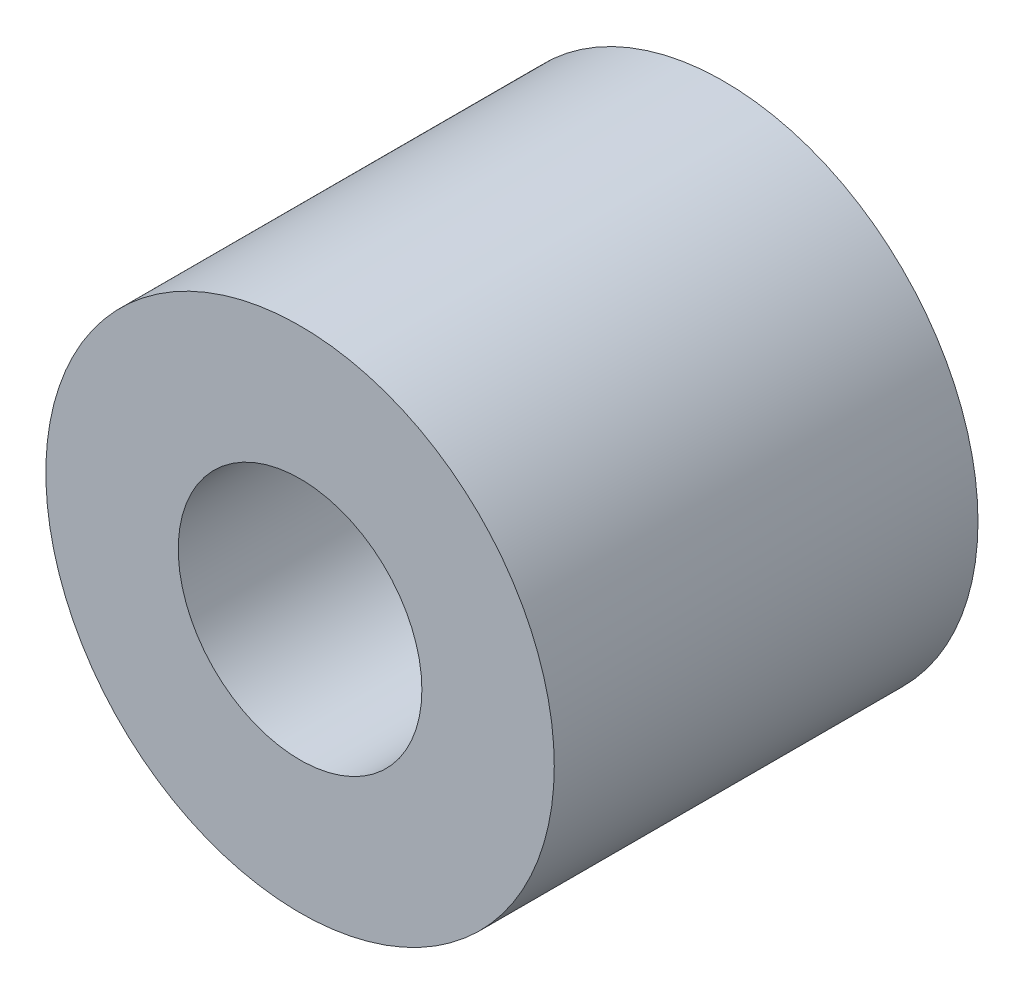
from build123d import *

# Parameters (mm, degrees)
SKETCH_1_R      = 2.4
SKETCH_1_R_2    = 1.15
EXTRUDE_2_DEPTH = 4


with BuildPart() as part:
    # 草图1 → 凸台-拉伸2 (new body)
    with BuildSketch(Plane.XY):
        Circle(SKETCH_1_R)
        Circle(SKETCH_1_R_2, mode=Mode.SUBTRACT)
    extrude(amount=EXTRUDE_2_DEPTH)


solid = part.part
